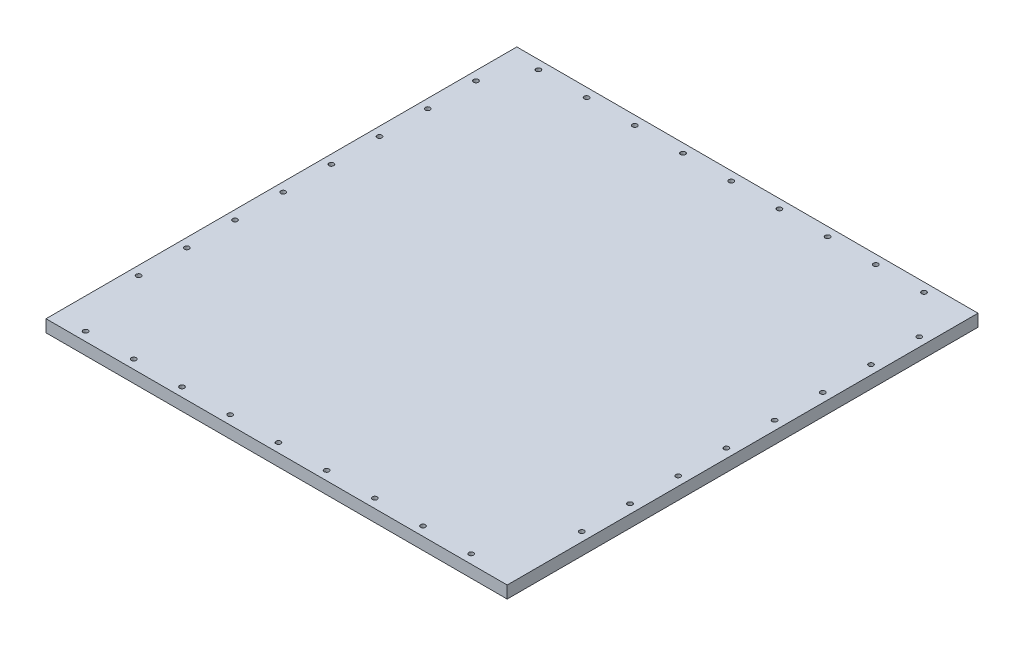
from build123d import *

# Parameters (mm, degrees)
SKETCH1_W           = 480
SKETCH1_H           = 490
BOSS_EXTRUDE1_DEPTH = 12.7
CUT_EXTRUDE2_START  = -13.7
SKETCH4_R           = 2.5
CUT_EXTRUDE2_DEPTH  = 14.7
LPATTERN3_COUNT     = 10
LPATTERN3_PITCH     = 50.159999979
CUT_EXTRUDE3_START  = -13.7
SKETCH5_R           = 2.5
CUT_EXTRUDE3_DEPTH  = 14.7
LPATTERN4_COUNT     = 8
LPATTERN4_PITCH     = 50.159999979
CUT_EXTRUDE4_START  = -13.7
SKETCH6_R           = 2.5
CUT_EXTRUDE4_DEPTH  = 14.7
LPATTERN5_COUNT     = 10
LPATTERN5_PITCH     = 50.159999979
CUT_EXTRUDE5_START  = -13.7
SKETCH7_R           = 2.5
CUT_EXTRUDE5_DEPTH  = 14.7
LPATTERN6_COUNT     = 8
LPATTERN6_PITCH     = 50.159999979


with BuildPart() as part:
    # Sketch1 → Boss-Extrude1 (new body)
    with BuildSketch(Plane(origin=(0, 0, 0), x_dir=(1, 0, 0), z_dir=(0, 1, 0))):
        Rectangle(SKETCH1_W, SKETCH1_H)
    extrude(amount=BOSS_EXTRUDE1_DEPTH)

    # Sketch4 → Cut-Extrude2 (cut)
    with BuildSketch(Plane(origin=(0, 12.7, 0), x_dir=(1, 0, 0), z_dir=(0, 1, 0)).offset(CUT_EXTRUDE2_START)):
        with Locations((-208.14, 235.640000004)):
            Circle(SKETCH4_R)
    cut_extrude2 = extrude(amount=CUT_EXTRUDE2_DEPTH, mode=Mode.SUBTRACT)

    # LPattern3: Cut-Extrude2 ×10
    with Locations(*[(i * LPATTERN3_PITCH, 0, 0) for i in range(1, LPATTERN3_COUNT)]):
        add(cut_extrude2, mode=Mode.SUBTRACT)

    # Sketch5 → Cut-Extrude3 (cut)
    with BuildSketch(Plane(origin=(0, 12.7, 0), x_dir=(1, 0, 0), z_dir=(0, 1, 0)).offset(CUT_EXTRUDE3_START)):
        with Locations((-230.640000004, 193.14)):
            Circle(SKETCH5_R)
    cut_extrude3 = extrude(amount=CUT_EXTRUDE3_DEPTH, mode=Mode.SUBTRACT)

    # LPattern4: Cut-Extrude3 ×8
    with Locations(*[(0, 0, i * LPATTERN4_PITCH) for i in range(1, LPATTERN4_COUNT)]):
        add(cut_extrude3, mode=Mode.SUBTRACT)

    # Sketch6 → Cut-Extrude4 (cut)
    with BuildSketch(Plane(origin=(0, 12.7, 0), x_dir=(1, 0, 0), z_dir=(0, 1, 0)).offset(CUT_EXTRUDE4_START)):
        with Locations((-208.14, -235.640000004)):
            Circle(SKETCH6_R)
    cut_extrude4 = extrude(amount=CUT_EXTRUDE4_DEPTH, mode=Mode.SUBTRACT)

    # LPattern5: Cut-Extrude4 ×10
    with Locations(*[(i * LPATTERN5_PITCH, 0, 0) for i in range(1, LPATTERN5_COUNT)]):
        add(cut_extrude4, mode=Mode.SUBTRACT)

    # Sketch7 → Cut-Extrude5 (cut)
    with BuildSketch(Plane(origin=(0, 12.7, 0), x_dir=(1, 0, 0), z_dir=(0, 1, 0)).offset(CUT_EXTRUDE5_START)):
        with Locations((230.64, 193.14)):
            Circle(SKETCH7_R)
    cut_extrude5 = extrude(amount=CUT_EXTRUDE5_DEPTH, mode=Mode.SUBTRACT)

    # LPattern6: Cut-Extrude5 ×8
    with Locations(*[(0, 0, i * LPATTERN6_PITCH) for i in range(1, LPATTERN6_COUNT)]):
        add(cut_extrude5, mode=Mode.SUBTRACT)


solid = part.part
